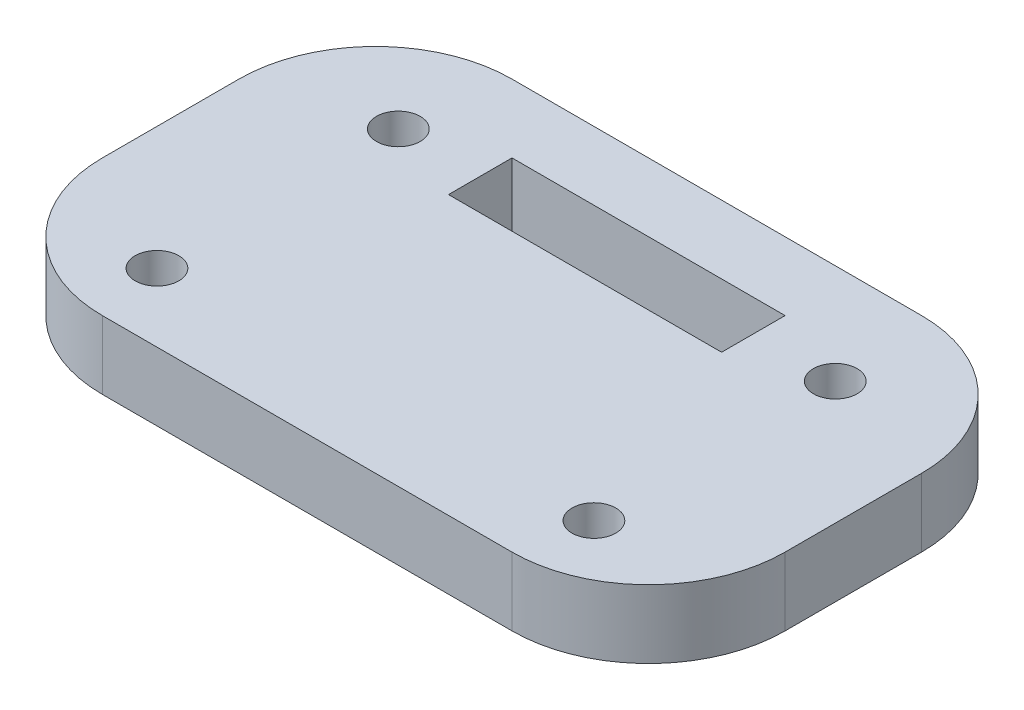
from build123d import *

# Parameters (mm, degrees)
SKETCH2_R           = 1.6
SKETCH2_W           = 20
SKETCH2_H           = 4.65
BOSS_EXTRUDE1_DEPTH = 5


with BuildPart() as part:
    # Sketch2 → Boss-Extrude1 (new body)
    with BuildSketch(Plane(origin=(0, 0, 0), x_dir=(1, 0, 0), z_dir=(0, 1, 0))):
        with BuildLine():
            Line((10, 0), (40, 0))
            ThreePointArc((40, 0), (47.071067812, 2.928932188), (50, 10))
            Line((50, 10), (50, 20))
            ThreePointArc((50, 20), (47.071067812, 27.071067812), (40, 30))
            Line((40, 30), (10, 30))
            ThreePointArc((10, 30), (2.928932188, 27.071067812), (0, 20))
            Line((0, 20), (0, 10))
            ThreePointArc((0, 10), (2.928932188, 2.928932188), (10, 0))
        make_face()
        with Locations((9, 5)):
            Circle(SKETCH2_R, mode=Mode.SUBTRACT)
        with Locations((41, 5)):
            Circle(SKETCH2_R, mode=Mode.SUBTRACT)
        with Locations((9, 22.675)):
            Circle(SKETCH2_R, mode=Mode.SUBTRACT)
        with Locations((41, 22.675)):
            Circle(SKETCH2_R, mode=Mode.SUBTRACT)
        with Locations((25, 22.675)):
            Rectangle(SKETCH2_W, SKETCH2_H, mode=Mode.SUBTRACT)
    extrude(amount=BOSS_EXTRUDE1_DEPTH)


solid = part.part
